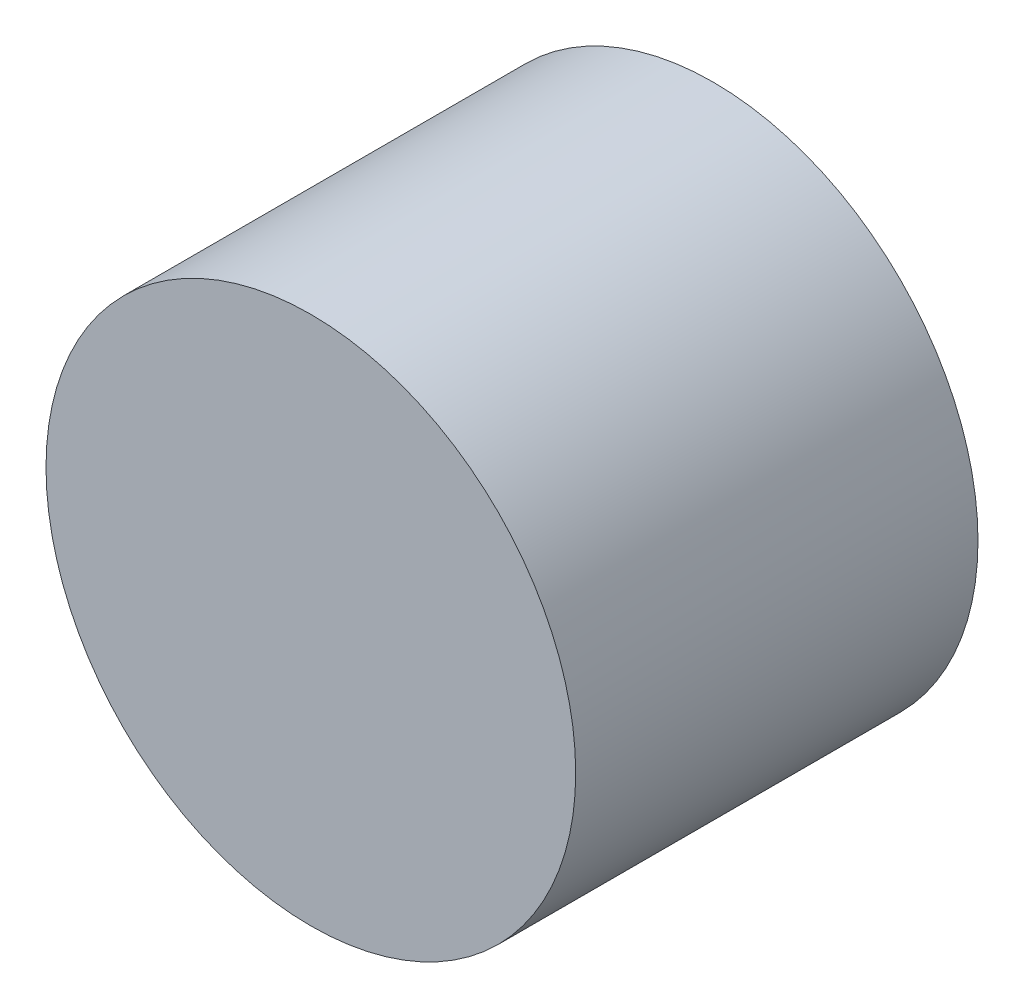
from build123d import *

# Parameters (mm, degrees)
SKETCH1_R           = 7.9
SKETCH1_R_2         = 5.5
BOSS_EXTRUDE1_DEPTH = 2
SKETCH2_R           = 7.9
SKETCH2_R_2         = 5.5
BOSS_EXTRUDE2_DEPTH = 10


with BuildPart() as part:
    # Sketch1 → Boss-Extrude1 (new body)
    with BuildSketch(Plane.XY):
        Circle(SKETCH1_R)
        Circle(SKETCH1_R_2, mode=Mode.SUBTRACT)
        Circle(SKETCH1_R_2)
    extrude(amount=BOSS_EXTRUDE1_DEPTH)

    # Sketch2 → Boss-Extrude2 (add)
    with BuildSketch(Plane(origin=(0, 0, 0), x_dir=(-1, 0, 0), z_dir=(0, 0, -1))):
        Circle(SKETCH2_R)
        Circle(SKETCH2_R_2, mode=Mode.SUBTRACT)
    extrude(amount=BOSS_EXTRUDE2_DEPTH)


solid = part.part
